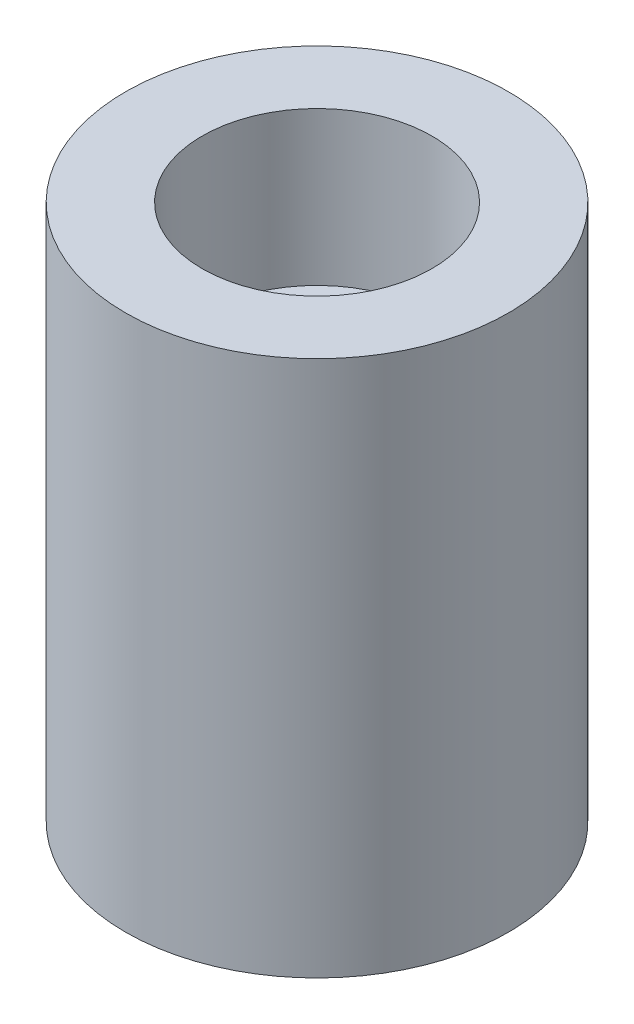
from build123d import *

# Parameters (mm, degrees)
SKETCH3_R           = 50
BOSS_EXTRUDE3_DEPTH = 140
SKETCH4_R           = 30
CUT_EXTRUDE1_DEPTH  = 40
SKETCH5_R           = 10
CUT_EXTRUDE2_DEPTH  = 80


with BuildPart() as part:
    # Sketch3 → Boss-Extrude3 (new body)
    with BuildSketch(Plane(origin=(0, 0, 0), x_dir=(1, 0, 0), z_dir=(0, 1, 0))):
        with Locations(Location((0, 0, 0), (0, 0, 270))):  # turned: the seam where the file's is
            Circle(SKETCH3_R)
    extrude(amount=BOSS_EXTRUDE3_DEPTH)

    # Sketch4 → Cut-Extrude1 (cut)
    with BuildSketch(Plane(origin=(0, 140, 0), x_dir=(1, 0, 0), z_dir=(0, 1, 0))):
        with Locations(Location((0, 0, 0), (0, 0, 270))):  # turned: the seam where the file's is
            Circle(SKETCH4_R)
    extrude(amount=-CUT_EXTRUDE1_DEPTH, mode=Mode.SUBTRACT)

    # Sketch5 → Cut-Extrude2 (cut)
    with BuildSketch(Plane(origin=(0, 100, 0), x_dir=(1, 0, 0), z_dir=(0, 1, 0))):
        with Locations(Location((0, 0, 0), (0, 0, 270))):  # turned: the seam where the file's is
            Circle(SKETCH5_R)
    extrude(amount=-CUT_EXTRUDE2_DEPTH, mode=Mode.SUBTRACT)


solid = part.part
